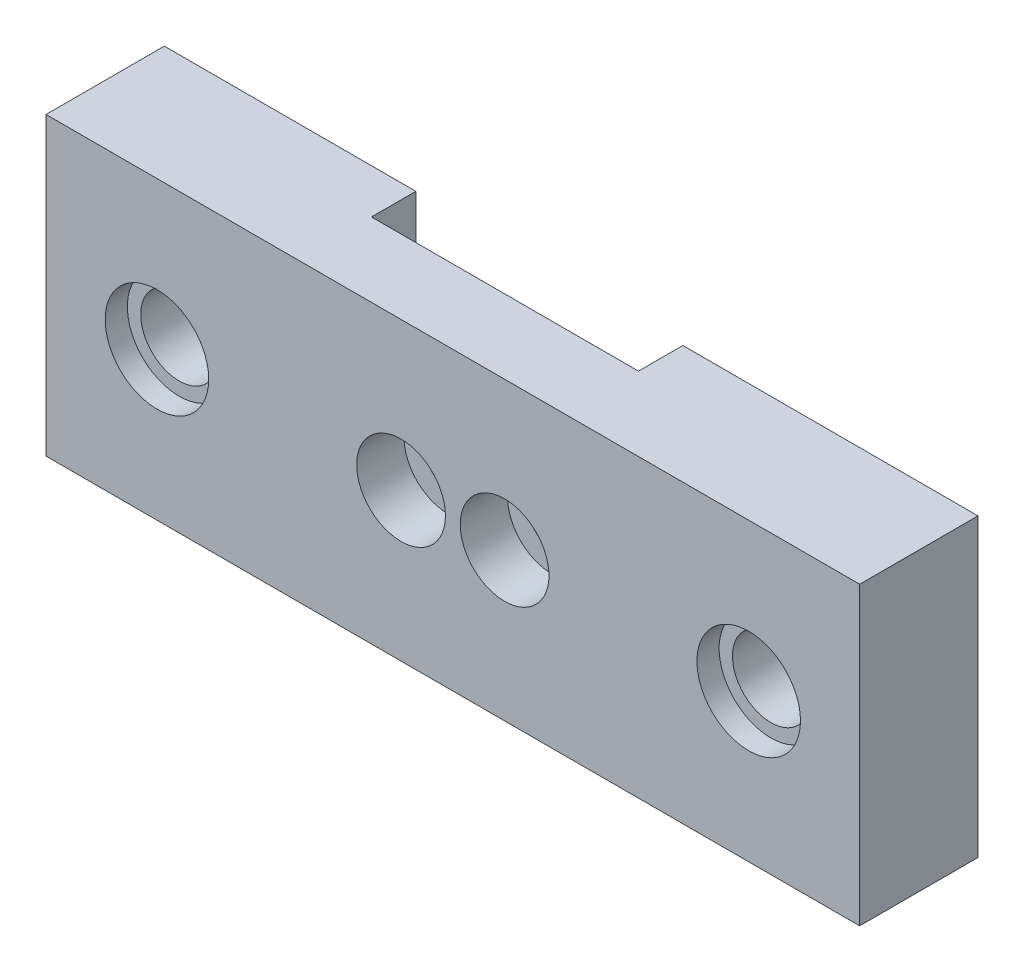
from build123d import *

# Parameters (mm, degrees)
ESQUISSE1_W             = 55
ESQUISSE1_H             = 20
ESQUISSE1_R             = 2.6
ESQUISSE1_R_2           = 1.55
EXTRUSION1_DEPTH        = 8
ESQUISSE2_R             = 3.5
ENL_V_MAT_EXTRU_1_DEPTH = 1.5
ESQUISSE3_R             = 3
ENL_V_MAT_EXTRU_2_DEPTH = 3.2
ESQUISSE4_R             = 1.55
ENL_V_MAT_EXTRU_3_DEPTH = 3


with BuildPart() as part:
    # Esquisse1 → Extrusion1 (new body)
    with BuildSketch(Plane.XY):
        Rectangle(ESQUISSE1_W, ESQUISSE1_H)
        with Locations((-20, 0)):
            Circle(ESQUISSE1_R, mode=Mode.SUBTRACT)
        with Locations((20, 0)):
            Circle(ESQUISSE1_R, mode=Mode.SUBTRACT)
        with Locations((-3.5, 0)):
            Circle(ESQUISSE1_R_2, mode=Mode.SUBTRACT)
        with Locations((3.5, 0)):
            Circle(ESQUISSE1_R_2, mode=Mode.SUBTRACT)
    extrude(amount=EXTRUSION1_DEPTH)

    # Esquisse2 → Enlèv. mat.-Extru.1 (cut)
    with BuildSketch(Plane.XY.offset(8)):
        with Locations((-20, 0)):
            Circle(ESQUISSE2_R)
        with Locations((20, 0)):
            Circle(ESQUISSE2_R)
    extrude(amount=-ENL_V_MAT_EXTRU_1_DEPTH, mode=Mode.SUBTRACT)

    # Esquisse3 → Enlèv. mat.-Extru.2 (cut)
    with BuildSketch(Plane.XY.offset(8)):
        with Locations((-3.5, 0)):
            Circle(ESQUISSE3_R)
        with Locations((3.5, 0)):
            Circle(ESQUISSE3_R)
    extrude(amount=-ENL_V_MAT_EXTRU_2_DEPTH, mode=Mode.SUBTRACT)

    # Esquisse4 → Enlèv. mat.-Extru.3 (cut)
    with BuildSketch(Plane(origin=(0, 0, 0), x_dir=(-1, 0, 0), z_dir=(0, 0, -1))):
        with BuildLine():
            Line((-7.55, 10), (-7.55, -10))
            Line((-7.55, -10), (7.55, -10))
            Line((7.55, -10), (7.55, 3.000416696))
            ThreePointArc((7.55, 3.000416696), (9.638924964, 3.896431603), (10.5, 6))
            Line((10.5, 6), (10.5, 10))
            Line((10.5, 10), (-7.55, 10))
        make_face()
        with Locations((-3.5, 0)):
            Circle(ESQUISSE4_R, mode=Mode.SUBTRACT)
        with Locations((3.5, 0)):
            Circle(ESQUISSE4_R, mode=Mode.SUBTRACT)
    extrude(amount=-ENL_V_MAT_EXTRU_3_DEPTH, mode=Mode.SUBTRACT)


solid = part.part
